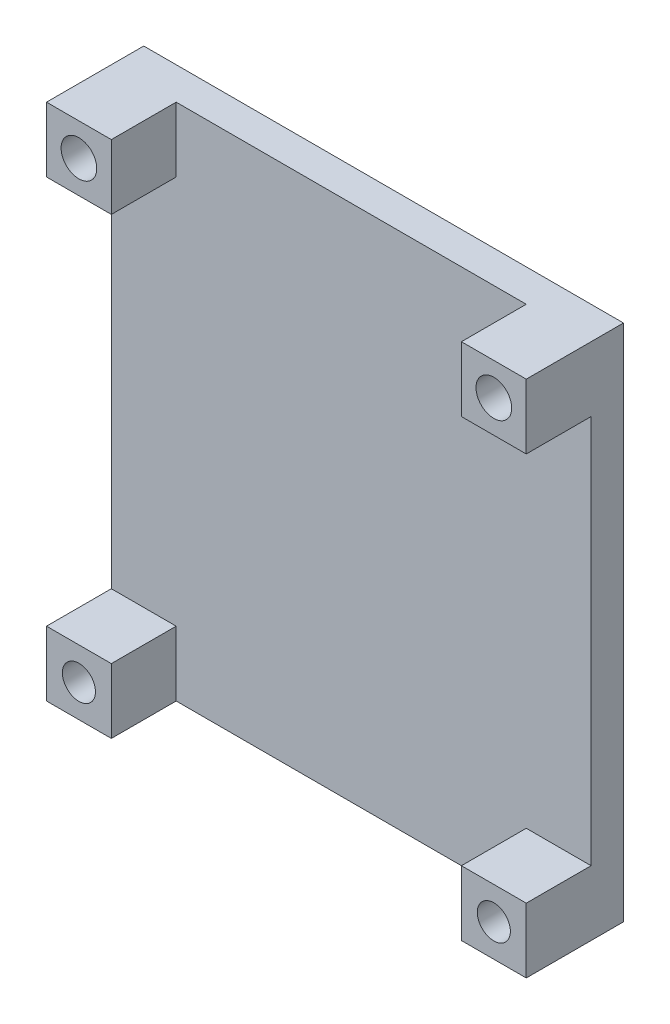
from build123d import *

# Parameters (mm, degrees)
CROQUIS1_W              = 74
CROQUIS1_H              = 80
SALIENTE_EXTRUIR1_DEPTH = 5
CROQUIS2_W              = 10
CROQUIS2_H              = 10
CROQUIS2_R              = 2.75
CROQUIS2_R_2            = 2.55
SALIENTE_EXTRUIR2_DEPTH = 10


with BuildPart() as part:
    # Croquis1 → Saliente-Extruir1 (new body)
    with BuildSketch(Plane.XY):
        with Locations((-29.301889279, 1.236374696)):
            Rectangle(CROQUIS1_W, CROQUIS1_H)
    extrude(amount=SALIENTE_EXTRUIR1_DEPTH)

    # Croquis2 → Saliente-Extruir2 (add)
    with BuildSketch(Plane.XY.offset(5)):
        with Locations((-61.301889279, 36.236374696)):
            Rectangle(CROQUIS2_W, CROQUIS2_H)
        with Locations((-61.301889279, 36.236374696)):
            Circle(CROQUIS2_R, mode=Mode.SUBTRACT)
        with Locations((2.698110721, 36.236374696)):
            Rectangle(CROQUIS2_W, CROQUIS2_H)
        with Locations((2.698110721, 36.236374696)):
            Circle(CROQUIS2_R, mode=Mode.SUBTRACT)
        with Locations((2.698110721, -33.763625304)):
            Rectangle(CROQUIS2_W, CROQUIS2_H)
        with Locations((2.698110721, -33.763625304)):
            Circle(CROQUIS2_R_2, mode=Mode.SUBTRACT)
        with Locations((-61.301889279, -33.763625304)):
            Rectangle(CROQUIS2_W, CROQUIS2_H)
        with Locations((-61.301889279, -33.763625304)):
            Circle(CROQUIS2_R_2, mode=Mode.SUBTRACT)
    extrude(amount=SALIENTE_EXTRUIR2_DEPTH)


solid = part.part
